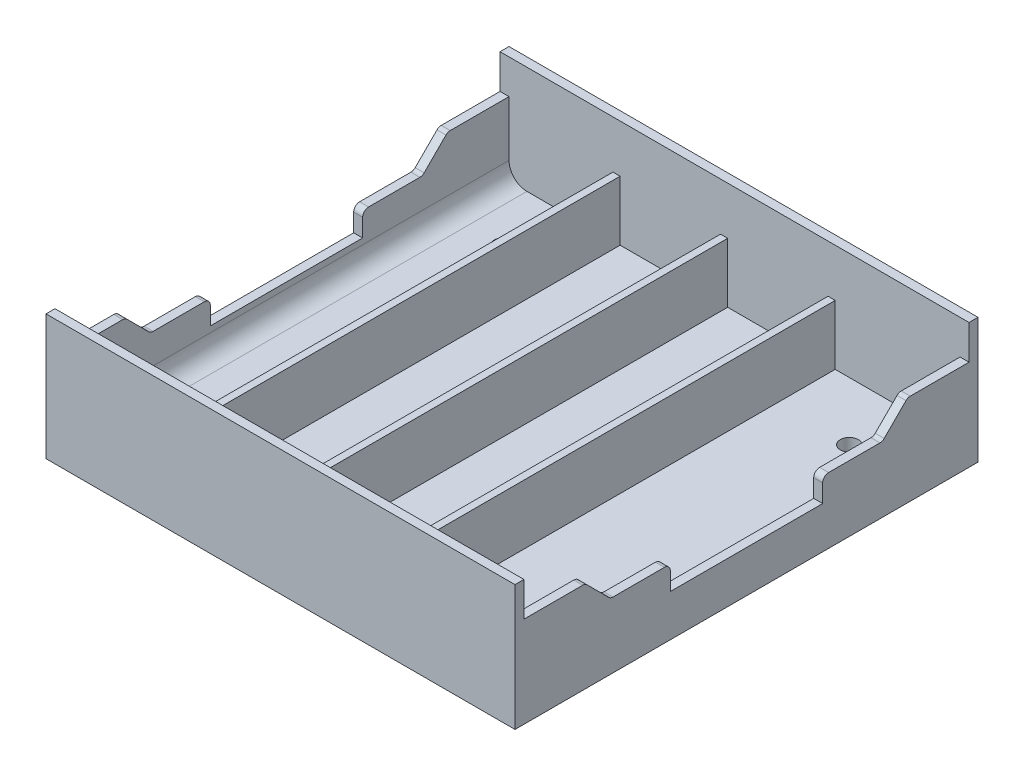
from build123d import *

# Parameters (mm, degrees)
SKETCH1_W             = 78.5
SKETCH1_H             = 77.5
BOSS_EXTRUDE1_DEPTH   = 21
SKETCH2_W             = 75.5
SKETCH2_H             = 74.5
CUT_EXTRUDE1_DEPTH    = 18
CUT_EXTRUDE2_DEPTH    = 113.292029993
RIB2_REACH            = 113.074
SKETCH5_WALLS_W       = 1.2
SKETCH5_WALLS_H       = 298.648598916
FILLET1_R             = 3
F_3_0MM_DOWEL_HOLE1_D = 3


with BuildPart() as part:
    # Sketch1 → Boss-Extrude1 (new body)
    with BuildSketch(Plane(origin=(0, 0, 0), x_dir=(1, 0, 0), z_dir=(0, 1, 0))):
        with Locations((39.25, 38.75)):
            Rectangle(SKETCH1_W, SKETCH1_H)
    extrude(amount=BOSS_EXTRUDE1_DEPTH)

    # Sketch2 → Cut-Extrude1 (cut)
    with BuildSketch(Plane(origin=(0, 21, 0), x_dir=(1, 0, 0), z_dir=(0, 1, 0))):
        with Locations((39.25, 38.75)):
            Rectangle(SKETCH2_W, SKETCH2_H)
    extrude(amount=-CUT_EXTRUDE1_DEPTH, mode=Mode.SUBTRACT)

    # Sketch3 → Cut-Extrude2 (cut, through all)
    with BuildSketch(Plane(origin=(78.5, 0, 0), x_dir=(0, 0, -1), z_dir=(1, 0, 0))):
        with BuildLine():
            Line((26, 7), (51.5, 7))
            Line((51.5, 7), (51.5, 10))
            ThreePointArc((51.5, 10), (51.792893219, 10.707106781), (52.5, 11))
            Line((52.5, 11), (61.085786438, 11))
            ThreePointArc((61.085786438, 11), (61.46846987, 11.076120467), (61.792893219, 11.292893219))
            Line((61.792893219, 11.292893219), (65.449747468, 14.949747468))
            ThreePointArc((65.449747468, 14.949747468), (65.774170817, 15.16652022), (66.156854249, 15.242640687))
            Line((66.156854249, 15.242640687), (76, 15.242640687))
            Line((76, 15.242640687), (76, 21))
            Line((76, 21), (1.5, 21))
            Line((1.5, 21), (1.5, 15.242640687))
            Line((1.5, 15.242640687), (11.343145751, 15.242640687))
            ThreePointArc((11.343145751, 15.242640687), (11.725829183, 15.16652022), (12.050252532, 14.949747468))
            Line((12.050252532, 14.949747468), (15.707106781, 11.292893219))
            ThreePointArc((15.707106781, 11.292893219), (16.03153013, 11.076120467), (16.414213562, 11))
            Line((16.414213562, 11), (25, 11))
            ThreePointArc((25, 11), (25.707106781, 10.707106781), (26, 10))
            Line((26, 10), (26, 7))
        make_face()
    extrude(amount=-CUT_EXTRUDE2_DEPTH, mode=Mode.SUBTRACT)

    # Sketch5 walls → Rib2 (add, up to next)
    with BuildSketch(Plane(origin=(0, 13, 0), x_dir=(1, 0, 0), z_dir=(0, 1, 0)), mode=Mode.PRIVATE) as rib2_sk1:
        with Locations((19.5, 38.75)):
            Rectangle(SKETCH5_WALLS_W, SKETCH5_WALLS_H)
    rib2_tool1 = extrude(rib2_sk1.sketch, amount=-RIB2_REACH, mode=Mode.PRIVATE) - part.part
    # Sketch5 walls → Rib2 (add, up to next)
    with BuildSketch(Plane(origin=(0, 13, 0), x_dir=(1, 0, 0), z_dir=(0, 1, 0)), mode=Mode.PRIVATE) as rib2_sk2:
        with Locations((37.5, 38.75)):
            Rectangle(SKETCH5_WALLS_W, SKETCH5_WALLS_H)
    rib2_tool2 = extrude(rib2_sk2.sketch, amount=-RIB2_REACH, mode=Mode.PRIVATE) - part.part
    # Sketch5 walls → Rib2 (add, up to next)
    with BuildSketch(Plane(origin=(0, 13, 0), x_dir=(1, 0, 0), z_dir=(0, 1, 0)), mode=Mode.PRIVATE) as rib2_sk3:
        with Locations((55.5, 38.75)):
            Rectangle(SKETCH5_WALLS_W, SKETCH5_WALLS_H)
    rib2_tool3 = extrude(rib2_sk3.sketch, amount=-RIB2_REACH, mode=Mode.PRIVATE) - part.part
    add(rib2_tool1.solids().sort_by_distance((19.5, 13, -38.75))[0])
    add(rib2_tool2.solids().sort_by_distance((37.5, 13, -38.75))[0])
    add(rib2_tool3.solids().sort_by_distance((55.5, 13, -38.75))[0])

    # Fillet1
    fillet1_edges = [part.edges().sort_by_distance(p)[0] for p in [
        (77, 3, -38.75),
        (1.5, 3, -38.75),
    ]]
    fillet(fillet1_edges, radius=FILLET1_R)

    # Ø3.0mm Dowel Hole1 (through all)
    with Locations(Plane(origin=(0, 0, 0), x_dir=(-1, 0, 0), z_dir=(0, -1, 0))):
        with Locations((-68.2, 11.25), (-48.9, 11.25), (-29.6, 11.25), (-10.3, 11.25), (-10.3, 66.25), (-29.6, 66.25), (-48.9, 66.25), (-68.2, 66.25)):
            Hole(F_3_0MM_DOWEL_HOLE1_D / 2)


solid = part.part
